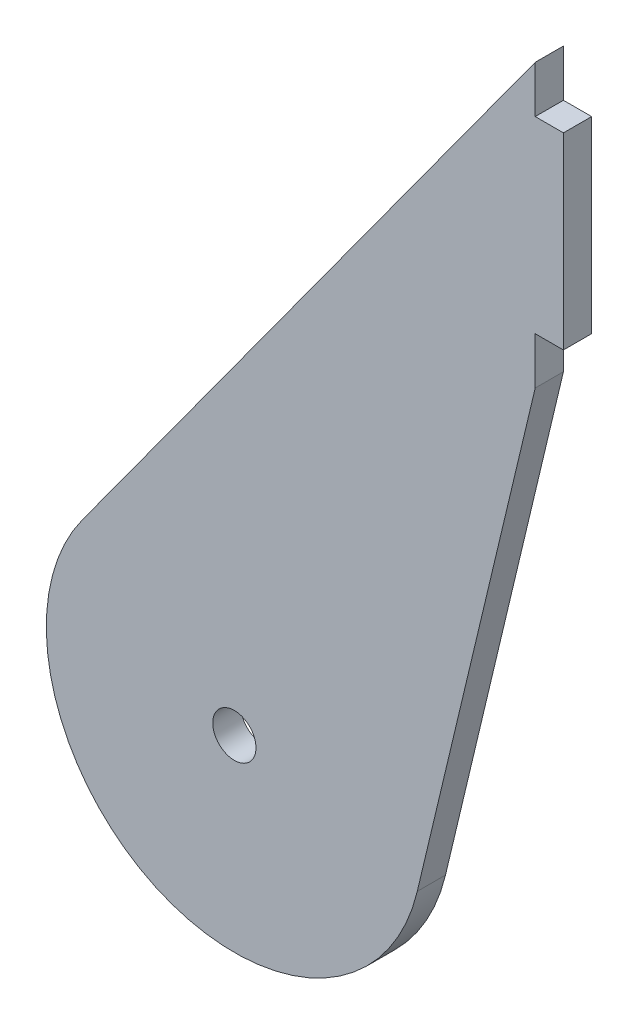
from build123d import *

# Parameters (mm, degrees)
BOSS_EXTRUDE1_DEPTH = 3
SKETCH2_R           = 2.3
CUT_EXTRUDE1_DEPTH  = 10
SKETCH4_W           = 3
SKETCH4_H           = 20
BOSS_EXTRUDE3_DEPTH = 3


with BuildPart() as part:
    # Sketch1 → Boss-Extrude1 (new body)
    with BuildSketch(Plane.XY):
        with BuildLine():
            Line((-16.174411119, 11.763860972), (32, 78))
            Line((32, 78), (32, 48))
            Line((32, 48), (19.455095298, -4.636730199))
            ThreePointArc((19.455095298, -4.636730199), (-8.362748941, -18.167675419), (-16.174411119, 11.763860972))
        make_face()
    extrude(amount=-BOSS_EXTRUDE1_DEPTH)

    # Sketch2 → Cut-Extrude1 (cut)
    with BuildSketch(Plane.XY):
        Circle(SKETCH2_R)
    extrude(amount=-CUT_EXTRUDE1_DEPTH, mode=Mode.SUBTRACT)

    # Sketch4 → Boss-Extrude3 (add)
    with BuildSketch(Plane(origin=(32, 0, 0), x_dir=(0, 0, -1), z_dir=(1, 0, 0))):
        with Locations((1.5, 63)):
            Rectangle(SKETCH4_W, SKETCH4_H)
    extrude(amount=BOSS_EXTRUDE3_DEPTH)


solid = part.part
